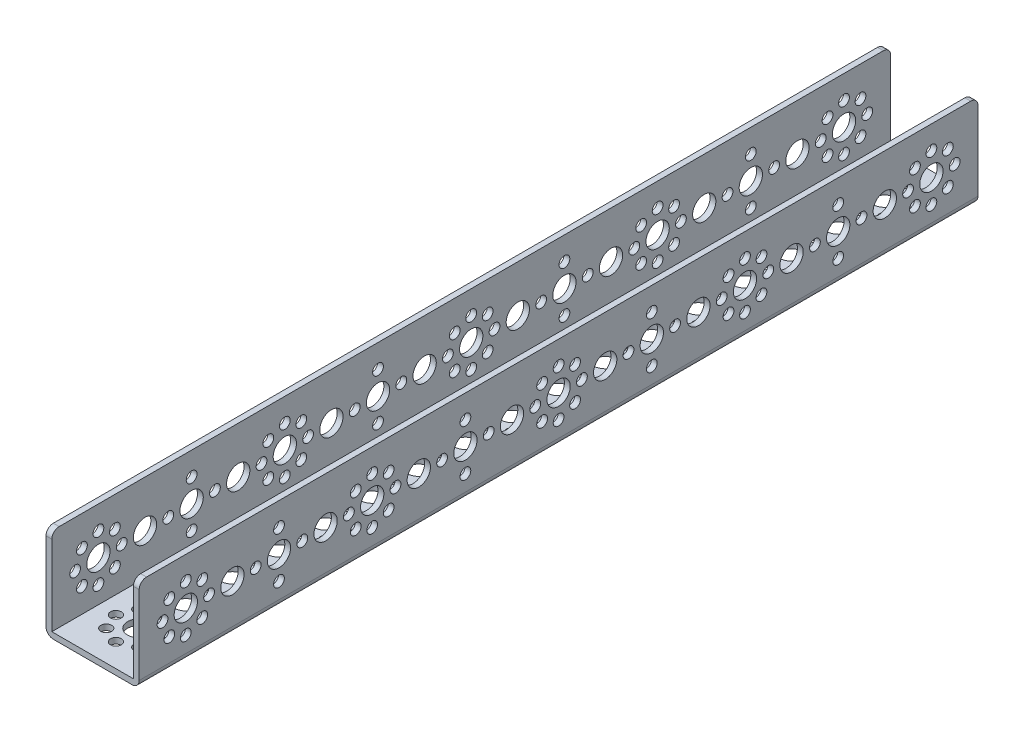
from build123d import *

# Parameters (mm, degrees)
SKETCH1_W                      = 288
SKETCH1_H                      = 32
BOSS_EXTRUDE1_DEPTH            = 32
SKETCH2_W                      = 28
SKETCH2_H                      = 30
CUT_EXTRUDE1_DEPTH             = 289
F_8_0_8_DIAMETER_HOLE1_D       = 8
F_8_0_8_DIAMETER_HOLE1_DEPTH   = 2
F_3_7_3_7_DIAMETER_HOLE1_D     = 3.7
F_3_7_3_7_DIAMETER_HOLE1_DEPTH = 2
F_3_7_3_7_DIAMETER_HOLE2_D     = 3.7
F_3_7_3_7_DIAMETER_HOLE2_DEPTH = 32
F_8_0_8_DIAMETER_HOLE2_D       = 8
F_8_0_8_DIAMETER_HOLE2_DEPTH   = 32
F_8_0_8_DIAMETER_HOLE3_D       = 8
F_8_0_8_DIAMETER_HOLE3_DEPTH   = 2
F_8_0_8_DIAMETER_HOLE4_D       = 8
F_8_0_8_DIAMETER_HOLE4_DEPTH   = 32
F_3_7_3_7_DIAMETER_HOLE3_D     = 3.7
F_3_7_3_7_DIAMETER_HOLE3_DEPTH = 32
FILLET1_R                      = 2.5


with BuildPart() as part:
    # Sketch1 → Boss-Extrude1 (new body)
    with BuildSketch(Plane(origin=(16, 0, 0), x_dir=(0, 0, -1), z_dir=(1, 0, 0))):
        with Locations((128, 16)):
            Rectangle(SKETCH1_W, SKETCH1_H)
    extrude(amount=-BOSS_EXTRUDE1_DEPTH)

    # Sketch2 → Cut-Extrude1 (cut, through all)
    with BuildSketch(Plane(origin=(0, 0, -272), x_dir=(-1, 0, 0), z_dir=(0, 0, -1))):
        with Locations((0, 17)):
            Rectangle(SKETCH2_W, SKETCH2_H)
    extrude(amount=-CUT_EXTRUDE1_DEPTH, mode=Mode.SUBTRACT)

    # Ø8.0 (8) Diameter Hole1
    with Locations(Plane.ZY.offset(16)):
        with Locations((-64, 16), (-128, 16), (-192, 16), (-256, 16), (-32, 16), (-96, 16), (-160, 16), (-224, 16), (-16, 16), (-48, 16), (-80, 16), (-112, 16), (0, 16), (-144, 16), (-176, 16), (-208, 16), (-240, 16)):
            Hole(F_8_0_8_DIAMETER_HOLE1_D / 2, depth=F_8_0_8_DIAMETER_HOLE1_DEPTH)

    # Ø3.7 (3.7) Diameter Hole1
    with Locations(Plane.ZY.offset(16)):
        with Locations((0, 24), (0, 8), (-8, 16), (8, 16), (-5.656854249, 21.656854249), (5.656854249, 21.656854249), (5.656854249, 10.343145751), (-5.656854249, 10.343145751), (-64, 24), (-64, 8), (-72, 16), (-56, 16), (-69.656854249, 21.656854249), (-58.343145751, 21.656854249), (-58.343145751, 10.343145751), (-69.656854249, 10.343145751), (-128, 24), (-128, 8), (-136, 16), (-120, 16), (-133.656854249, 21.656854249), (-122.34314575, 21.656854249), (-122.34314575, 10.343145751), (-133.656854249, 10.343145751), (-192, 24), (-192, 8), (-200, 16), (-184, 16), (-197.656854249, 21.656854249), (-186.343145751, 21.656854249), (-186.343145751, 10.343145751), (-197.656854249, 10.343145751), (-256, 24), (-256, 8), (-264, 16), (-248, 16), (-261.656854249, 21.656854249), (-250.343145751, 21.656854249), (-250.343145751, 10.343145751), (-261.656854249, 10.343145751), (-32, 24), (-40, 16), (-32, 8), (-24, 16), (-96, 24), (-104, 16), (-96, 8), (-88, 16), (-160, 24), (-168, 16), (-160, 8), (-152, 16), (-224, 24), (-232, 16), (-224, 8), (-216, 16)):
            Hole(F_3_7_3_7_DIAMETER_HOLE1_D / 2, depth=F_3_7_3_7_DIAMETER_HOLE1_DEPTH)

    # Ø3.7 (3.7) Diameter Hole2
    with Locations(Plane(origin=(0, 0, 0), x_dir=(-1, 0, 0), z_dir=(0, -1, 0))):
        with Locations((8, 0), (5.656854249, 5.656854249), (0, 8), (-5.656854249, 5.656854249), (-8, 0), (-5.656854249, -5.656854249), (0, -8), (5.656854249, -5.656854249), (8, 64), (5.656854249, 69.656854249), (0, 72), (-5.656854249, 69.656854249), (-8, 64), (-5.656854249, 58.343145751), (0, 56), (5.656854249, 58.343145751), (8, 128), (5.656854249, 133.656854249), (0, 136), (-5.656854249, 133.656854249), (-8, 128), (-5.656854249, 122.34314575), (0, 120), (5.656854249, 122.34314575), (8, 192), (5.656854249, 197.656854249), (0, 200), (-5.656854249, 197.656854249), (-8, 192), (-5.656854249, 186.343145751), (0, 184), (5.656854249, 186.343145751), (8, 256), (5.656854249, 261.656854249), (0, 264), (-5.656854249, 261.656854249), (-8, 256), (-5.656854249, 250.343145751), (0, 248), (5.656854249, 250.343145751), (8, 32), (0, 40), (-8, 32), (0, 24), (8, 96), (0, 104), (-8, 96), (0, 88), (8, 160), (0, 168), (-8, 160), (0, 152), (8, 224), (0, 232), (-8, 224), (0, 216)):
            Hole(F_3_7_3_7_DIAMETER_HOLE2_D / 2, depth=F_3_7_3_7_DIAMETER_HOLE2_DEPTH)

    # Ø8.0 (8) Diameter Hole2
    with Locations(Plane(origin=(0, 0, 0), x_dir=(-1, 0, 0), z_dir=(0, -1, 0))):
        with Locations((0, 0), (0, 64), (0, 128), (0, 192), (0, 256), (0, 32), (0, 96), (0, 160), (0, 224), (0, 16), (0, 48), (0, 80), (0, 112), (0, 144), (0, 176), (0, 208), (0, 240)):
            Hole(F_8_0_8_DIAMETER_HOLE2_D / 2, depth=F_8_0_8_DIAMETER_HOLE2_DEPTH)

    # Ø8.0 (8) Diameter Hole3
    with Locations(Plane.ZY.offset(-14)):
        with Locations((-32, 16)):
            Hole(F_8_0_8_DIAMETER_HOLE3_D / 2, depth=F_8_0_8_DIAMETER_HOLE3_DEPTH)

    # Ø8.0 (8) Diameter Hole4
    with Locations(Plane(origin=(16, 0, 0), x_dir=(0, 0, -1), z_dir=(1, 0, 0))):
        with Locations((64, 16), (128, 16), (192, 16), (256, 16), (96, 16), (160, 16), (224, 16), (16, 16), (48, 16), (80, 16), (112, 16), (0, 16), (144, 16), (176, 16), (208, 16), (240, 16)):
            Hole(F_8_0_8_DIAMETER_HOLE4_D / 2, depth=F_8_0_8_DIAMETER_HOLE4_DEPTH)

    # Ø3.7 (3.7) Diameter Hole3
    with Locations(Plane(origin=(16, 0, 0), x_dir=(0, 0, -1), z_dir=(1, 0, 0))):
        with Locations((0, 24), (0, 8), (8, 16), (-8, 16), (5.656854249, 21.656854249), (-5.656854249, 21.656854249), (-5.656854249, 10.343145751), (5.656854249, 10.343145751), (64, 24), (64, 8), (72, 16), (56, 16), (69.656854249, 21.656854249), (58.343145751, 21.656854249), (58.343145751, 10.343145751), (69.656854249, 10.343145751), (128, 24), (128, 8), (136, 16), (120, 16), (133.656854249, 21.656854249), (122.34314575, 21.656854249), (122.34314575, 10.343145751), (133.656854249, 10.343145751), (192, 24), (192, 8), (200, 16), (184, 16), (197.656854249, 21.656854249), (186.343145751, 21.656854249), (186.343145751, 10.343145751), (197.656854249, 10.343145751), (256, 24), (256, 8), (264, 16), (248, 16), (261.656854249, 21.656854249), (250.343145751, 21.656854249), (250.343145751, 10.343145751), (261.656854249, 10.343145751), (32, 24), (40, 16), (32, 8), (24, 16), (96, 24), (104, 16), (96, 8), (88, 16), (160, 24), (168, 16), (160, 8), (152, 16), (224, 24), (232, 16), (224, 8), (216, 16)):
            Hole(F_3_7_3_7_DIAMETER_HOLE3_D / 2, depth=F_3_7_3_7_DIAMETER_HOLE3_DEPTH)

    # Fillet1
    fillet1_edges = [part.edges().sort_by_distance(p)[0] for p in [
        (-16, 0, -128),
        (15, 32, 16),
        (15, 32, -272),
        (16, 0, -128),
        (-15, 32, -272),
        (-15, 32, 16),
    ]]
    fillet(fillet1_edges, radius=FILLET1_R)


solid = part.part
